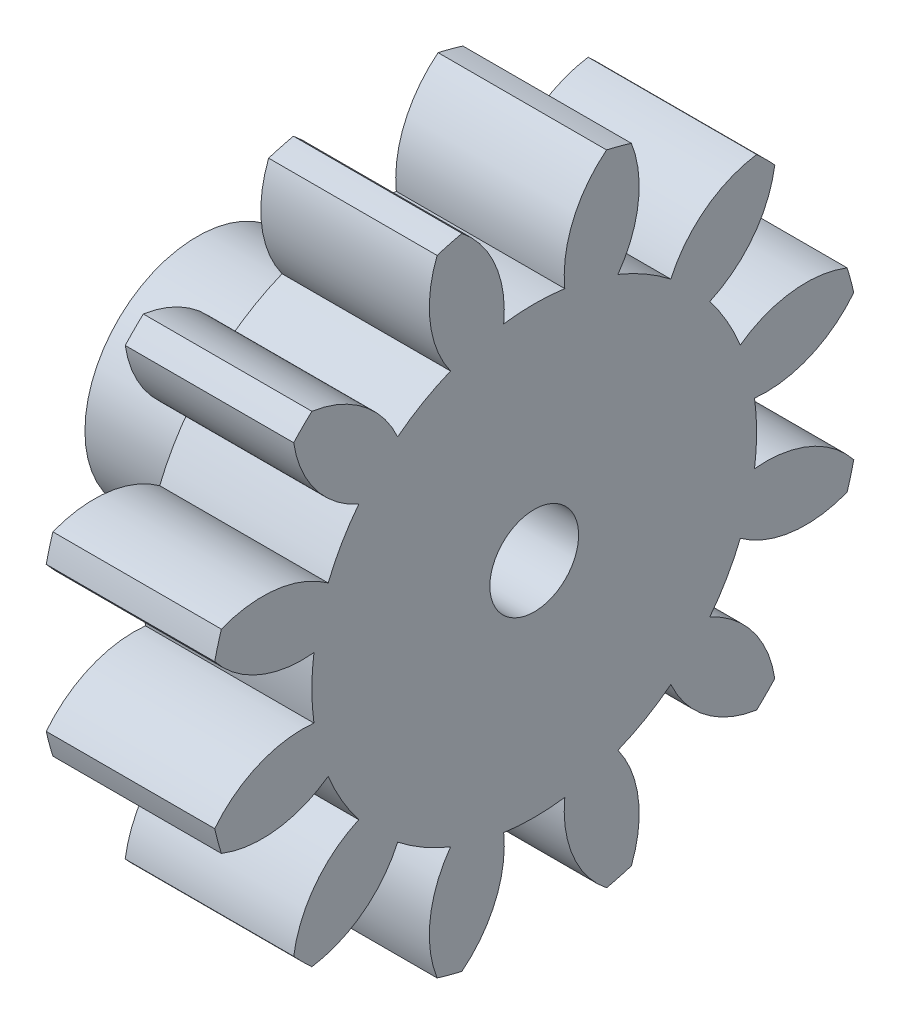
from build123d import *

# Parameters (mm, degrees)
BASPROSKE_W         = 3.81
BASPROSKE_H         = 7.408333333
TOOTHCUT_DEPTH      = 12.148224323
TEETHCUTS_COUNT     = 12
TEETHCUTS_ANGLE     = 330
BORSKE_R            = 5.0038
BORE_DEPTH          = 50.8000508
SKETCH1_R           = 5.0038
BOSS_EXTRUDE1_DEPTH = 3.81
SKETCH2_R           = 2.54
BOSS_EXTRUDE2_DEPTH = 3.81
SKETCH3_R           = 1.0033
CUT_EXTRUDE1_DEPTH  = 13.746829501


with BuildPart() as part:
    # BasProSke → Base-Revolve (revolve)
    with BuildSketch(Plane(origin=(0, 0, 0), x_dir=(1, 0, 0), z_dir=(0, 1, 0)), mode=Mode.PRIVATE) as base_revolve_sk:
        with Locations((1.905, 3.704166667)):
            Rectangle(BASPROSKE_W, BASPROSKE_H)
    revolve(base_revolve_sk.sketch.rotate(Axis((-10, 0, 0), (1, 0, 0)), 180), axis=Axis((-10, 0, 0), (1, 0, 0)))

    # TooCutSke → ToothCut (cut, through all)
    with BuildSketch(Plane(origin=(0, 0, 0), x_dir=(0, 0, -1), z_dir=(1, 0, 0))):
        with BuildLine():
            ThreePointArc((0.69063345, 4.981553782), (0, 5.0292), (-0.69063345, 4.981553782))
            ThreePointArc((-0.69063345, 4.981553782), (-0.883041418, 6.239186652), (-1.661175181, 7.245749671))
            ThreePointArc((-1.661175181, 7.245749671), (0, 7.433733333), (1.661175181, 7.245749671))
            ThreePointArc((1.661175181, 7.245749671), (0.883041418, 6.239186652), (0.69063345, 4.981553782))
        make_face()
    toothcut = extrude(amount=TOOTHCUT_DEPTH, mode=Mode.SUBTRACT)

    # TeethCuts: ToothCut ×12 about axis
    teethcuts_axis = Axis((-10, 0, 0), (1, 0, 0))
    for i in range(1, TEETHCUTS_COUNT):
        add(toothcut.rotate(teethcuts_axis, i * TEETHCUTS_ANGLE / (TEETHCUTS_COUNT - 1)), mode=Mode.SUBTRACT)

    # BorSke → Bore (cut, symmetric)
    with BuildSketch(Plane(origin=(0, 0, 0), x_dir=(0, 0, -1), z_dir=(1, 0, 0))):
        with Locations(Location((0, 0, 0), (0, 0, 180))):
            Circle(BORSKE_R)
    extrude(amount=BORE_DEPTH, both=True, mode=Mode.SUBTRACT)

    # Sketch1 → Boss-Extrude1 (add)
    with BuildSketch(Plane(origin=(0, 0, 0), x_dir=(0, 0, -1), z_dir=(1, 0, 0))):
        Circle(SKETCH1_R)
    extrude(amount=BOSS_EXTRUDE1_DEPTH)

    # Sketch2 → Boss-Extrude2 (add)
    with BuildSketch(Plane.ZY):
        with Locations(Location((0, 0, 0), (0, 0, 180))):
            Circle(SKETCH2_R)
    extrude(amount=BOSS_EXTRUDE2_DEPTH)

    # Sketch3 → Cut-Extrude1 (cut, through all)
    with BuildSketch(Plane.ZY.offset(3.81)):
        Circle(SKETCH3_R)
    extrude(amount=-CUT_EXTRUDE1_DEPTH, mode=Mode.SUBTRACT)


solid = part.part
